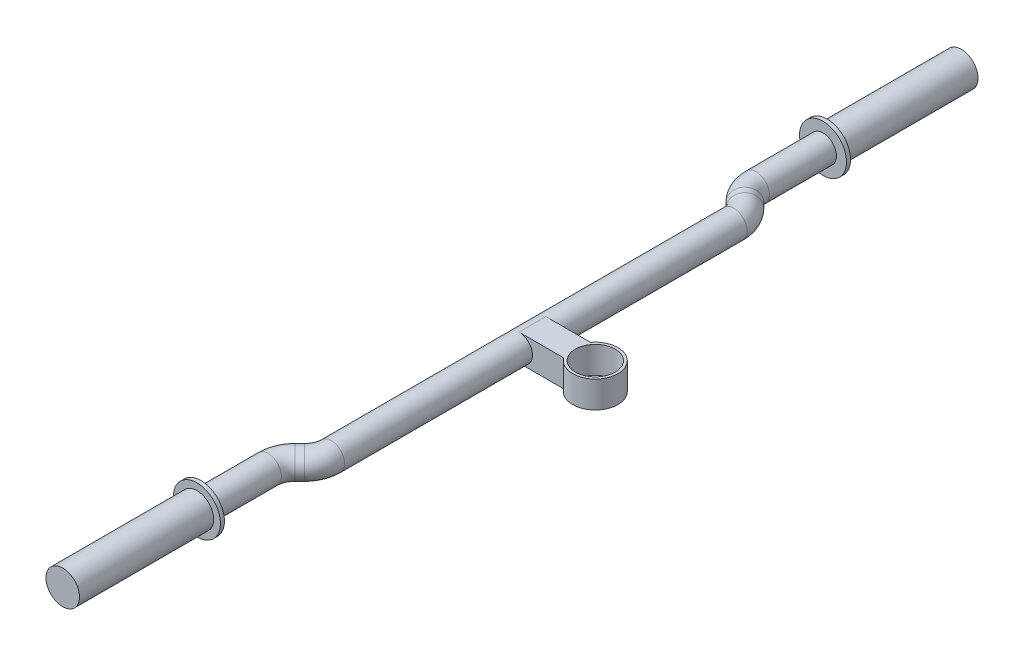
from build123d import *

# Parameters (mm, degrees)
SKETCH1_R           = 16.85
SKETCH1_R_2         = 14.85
BOSS_EXTRUDE1_DEPTH = 20
SKETCH2_R           = 10
SKETCH5_R           = 17.5
BOSS_EXTRUDE3_DEPTH = 3
SKETCH6_R           = 12.5
BOSS_EXTRUDE4_DEPTH = 100
BOSS_EXTRUDE2_DEPTH = 20
SKETCH7_R           = 17.5
BOSS_EXTRUDE5_DEPTH = 3
SKETCH8_R           = 12.5
BOSS_EXTRUDE6_DEPTH = 100


with BuildPart() as part:
    # Sketch1 → Boss-Extrude1 (new body)
    with BuildSketch(Plane(origin=(0, 0, 0), x_dir=(1, 0, 0), z_dir=(0, 1, 0))):
        with Locations(Location((0, 0, 0), (0, 0, 270))):
            Circle(SKETCH1_R)
        with Locations(Location((0, 0, 0), (0, 0, 270))):
            Circle(SKETCH1_R_2, mode=Mode.SUBTRACT)
    extrude(amount=BOSS_EXTRUDE1_DEPTH)

    # Sketch4 → Boss-Extrude2 (add)
    with BuildSketch(Plane(origin=(0, 20, 0), x_dir=(1, 0, 0), z_dir=(0, 1, 0))):
        with BuildLine():
            Line((-13.561802977, 10), (-46.85, 10))
            Line((-46.85, 10), (-46.85, -10))
            Line((-46.85, -10), (-13.561802977, -10))
            ThreePointArc((-13.561802977, -10), (-16.85, 0), (-13.561802977, 10))
        make_face()
    extrude(amount=-BOSS_EXTRUDE2_DEPTH)


with BuildPart() as body_2:
    # Sweep1: sweep along a path in Sketch3
    with BuildLine(Plane(origin=(0, 0, 0), x_dir=(1, 0, 0), z_dir=(0, 1, 0))) as sweep1_path:
        Line((-46.85, 0), (-46.85, -150))
        ThreePointArc((-46.85, -150), (-48.37240935, -157.653668647), (-52.707864376, -164.142135624))
        Line((-52.707864376, -164.142135624), (-56.243398282, -167.67766953))
        ThreePointArc((-56.243398282, -167.67766953), (-60.578853309, -174.166136506), (-62.101262658, -181.819805153))
        Line((-62.101262658, -181.819805153), (-62.101262658, -231.819805153))
    # Sketch2 → Sweep1 (sweep)
    with BuildSketch(Plane.XY):
        with Locations((-46.85, 10)):
            Circle(SKETCH2_R)
    sweep1 = sweep(path=sweep1_path.line)

    # Mirror1: Sweep1 across plane
    add(sweep1.mirror(Plane(origin=(-46.85, 10, 0), x_dir=(1, 0, 0), z_dir=(0, 0, 1))))


with BuildPart() as body_3:
    # Sketch5 → Boss-Extrude3 (new body)
    with BuildSketch(Plane.XY.offset(231.819805153)):
        with Locations((-62.101262658, 10)):
            Circle(SKETCH5_R)
    extrude(amount=BOSS_EXTRUDE3_DEPTH)

    # Sketch6 → Boss-Extrude4 (add)
    with BuildSketch(Plane.XY.offset(234.819805153)):
        with Locations((-62.101262658, 10)):
            Circle(SKETCH6_R)
    extrude(amount=BOSS_EXTRUDE4_DEPTH)


with BuildPart() as body_4:
    # Sketch7 → Boss-Extrude5 (new body)
    with BuildSketch(Plane(origin=(0, 0, -231.819805153), x_dir=(-1, 0, 0), z_dir=(0, 0, -1))):
        with Locations((62.101262658, 10)):
            Circle(SKETCH7_R)
    extrude(amount=BOSS_EXTRUDE5_DEPTH)

    # Sketch8 → Boss-Extrude6 (add)
    with BuildSketch(Plane(origin=(0, 0, -234.819805153), x_dir=(-1, 0, 0), z_dir=(0, 0, -1))):
        with Locations((62.101262658, 10)):
            Circle(SKETCH8_R)
    extrude(amount=BOSS_EXTRUDE6_DEPTH)


solid = Compound([part.part, body_2.part, body_3.part, body_4.part])
